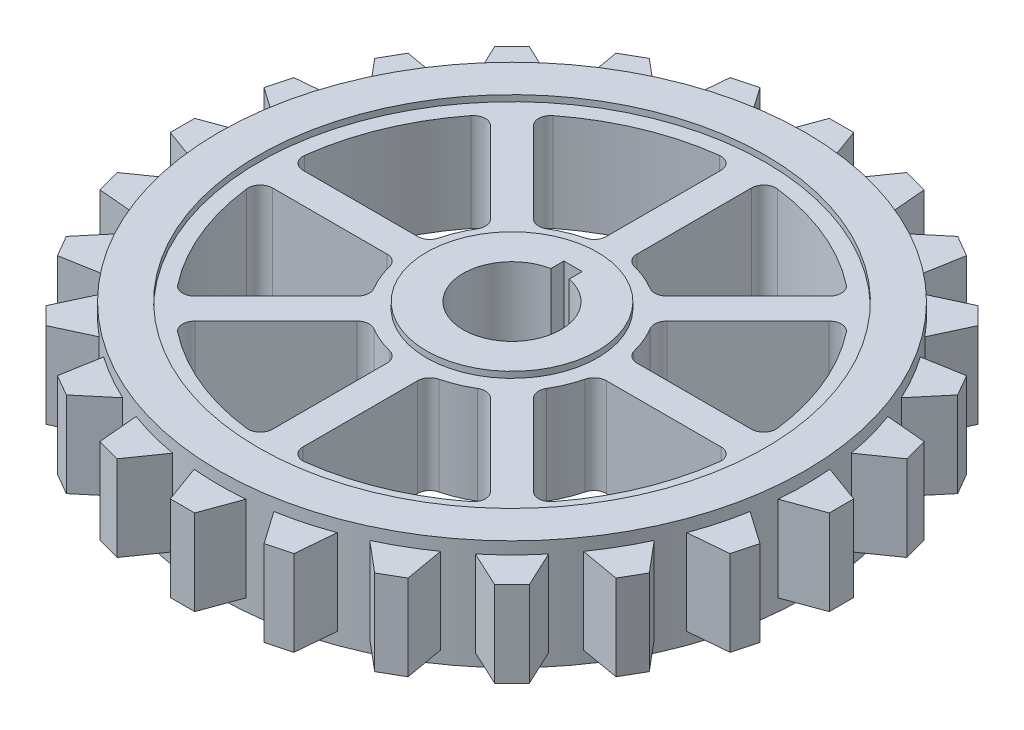
from build123d import *

# Parameters (mm, degrees)
BOSS_EXTRUDE1_DEPTH = 7
SKETCH1_4_R         = 48
SKETCH1_4_R_2       = 41.5
SKETCH1_4_R_3       = 14
BOSS_EXTRUDE2_DEPTH = 9
SKETCH1_5_R         = 41.5
SKETCH1_5_R_2       = 14
BOSS_EXTRUDE3_DEPTH = 8
FILLET2_R           = 2


with BuildPart() as part:
    # Sketch1 → Boss-Extrude1 (new, symmetric)
    with BuildSketch(Plane(origin=(0, 0, 0), x_dir=(1, 0, 0), z_dir=(0, 1, 0))):
        with BuildLine():
            ThreePointArc((8.280626141, 47.280347193), (6.265257227, 47.589353346), (4.238583665, 47.812492181))
            Line((4.238583665, 47.812492181), (2, 53.962950253))
            Line((2, 53.962950253), (-2, 53.962950253))
            Line((-2, 53.962950253), (-4.238583665, 47.812492181))
            ThreePointArc((-4.238583665, 47.812492181), (-6.265257227, 47.589353346), (-8.280626141, 47.280347193))
            Line((-8.280626141, 47.280347193), (-12.034787603, 52.641845402))
            Line((-12.034787603, 52.641845402), (-15.898490908, 51.606569222))
            Line((-15.898490908, 51.606569222), (-16.468940999, 45.08629484))
            ThreePointArc((-16.468940999, 45.08629484), (-18.368804754, 44.346217561), (-20.23552496, 43.526124679))
            Line((-20.23552496, 43.526124679), (-25.249424319, 47.733285782))
            Line((-25.249424319, 47.733285782), (-28.713525934, 45.733285782))
            Line((-28.713525934, 45.733285782), (-27.576967221, 39.287541014))
            ThreePointArc((-27.576967221, 39.287541014), (-29.220548592, 38.080960334), (-30.811406194, 36.805668699))
            Line((-30.811406194, 36.805668699), (-36.743354494, 39.571781619))
            Line((-36.743354494, 39.571781619), (-39.571781619, 36.743354494))
            Line((-39.571781619, 36.743354494), (-36.805668699, 30.811406194))
            ThreePointArc((-36.805668699, 30.811406194), (-38.080960334, 29.220548592), (-39.287541014, 27.576967221))
            Line((-39.287541014, 27.576967221), (-45.733285782, 28.713525934))
            Line((-45.733285782, 28.713525934), (-47.733285782, 25.249424319))
            Line((-47.733285782, 25.249424319), (-43.526124679, 20.23552496))
            ThreePointArc((-43.526124679, 20.23552496), (-44.346217561, 18.368804754), (-45.08629484, 16.468940999))
            Line((-45.08629484, 16.468940999), (-51.606569222, 15.898490908))
            Line((-51.606569222, 15.898490908), (-52.641845402, 12.034787603))
            Line((-52.641845402, 12.034787603), (-47.280347193, 8.280626141))
            ThreePointArc((-47.280347193, 8.280626141), (-47.589353346, 6.265257227), (-47.812492181, 4.238583665))
            Line((-47.812492181, 4.238583665), (-53.962950253, 2))
            Line((-53.962950253, 2), (-53.962950253, -2))
            Line((-53.962950253, -2), (-47.812492181, -4.238583665))
            ThreePointArc((-47.812492181, -4.238583665), (-47.589353346, -6.265257227), (-47.280347193, -8.280626141))
            Line((-47.280347193, -8.280626141), (-52.641845402, -12.034787603))
            Line((-52.641845402, -12.034787603), (-51.606569222, -15.898490908))
            Line((-51.606569222, -15.898490908), (-45.08629484, -16.468940999))
            ThreePointArc((-45.08629484, -16.468940999), (-44.346217561, -18.368804754), (-43.526124679, -20.23552496))
            Line((-43.526124679, -20.23552496), (-47.733285782, -25.249424319))
            Line((-47.733285782, -25.249424319), (-45.733285782, -28.713525934))
            Line((-45.733285782, -28.713525934), (-39.287541014, -27.576967221))
            ThreePointArc((-39.287541014, -27.576967221), (-38.080960334, -29.220548592), (-36.805668699, -30.811406194))
            Line((-36.805668699, -30.811406194), (-39.571781619, -36.743354494))
            Line((-39.571781619, -36.743354494), (-36.743354494, -39.571781619))
            Line((-36.743354494, -39.571781619), (-30.811406194, -36.805668699))
            ThreePointArc((-30.811406194, -36.805668699), (-29.220548592, -38.080960334), (-27.576967221, -39.287541014))
            Line((-27.576967221, -39.287541014), (-28.713525934, -45.733285782))
            Line((-28.713525934, -45.733285782), (-25.249424319, -47.733285782))
            Line((-25.249424319, -47.733285782), (-20.23552496, -43.526124679))
            ThreePointArc((-20.23552496, -43.526124679), (-18.368804754, -44.346217561), (-16.468940999, -45.08629484))
            Line((-16.468940999, -45.08629484), (-15.898490908, -51.606569222))
            Line((-15.898490908, -51.606569222), (-12.034787603, -52.641845402))
            Line((-12.034787603, -52.641845402), (-8.280626141, -47.280347193))
            ThreePointArc((-8.280626141, -47.280347193), (-6.265257227, -47.589353346), (-4.238583665, -47.812492181))
            Line((-4.238583665, -47.812492181), (-2, -53.962950253))
            Line((-2, -53.962950253), (2, -53.962950253))
            Line((2, -53.962950253), (4.238583665, -47.812492181))
            ThreePointArc((4.238583665, -47.812492181), (6.265257227, -47.589353346), (8.280626141, -47.280347193))
            Line((8.280626141, -47.280347193), (12.034787603, -52.641845402))
            Line((12.034787603, -52.641845402), (15.898490908, -51.606569222))
            Line((15.898490908, -51.606569222), (16.468940999, -45.08629484))
            ThreePointArc((16.468940999, -45.08629484), (18.368804754, -44.346217561), (20.23552496, -43.526124679))
            Line((20.23552496, -43.526124679), (25.249424319, -47.733285782))
            Line((25.249424319, -47.733285782), (28.713525934, -45.733285782))
            Line((28.713525934, -45.733285782), (27.576967221, -39.287541014))
            ThreePointArc((27.576967221, -39.287541014), (29.220548592, -38.080960334), (30.811406194, -36.805668699))
            Line((30.811406194, -36.805668699), (36.743354494, -39.571781619))
            Line((36.743354494, -39.571781619), (39.571781619, -36.743354494))
            Line((39.571781619, -36.743354494), (36.805668699, -30.811406194))
            ThreePointArc((36.805668699, -30.811406194), (38.080960334, -29.220548592), (39.287541014, -27.576967221))
            Line((39.287541014, -27.576967221), (45.733285782, -28.713525934))
            Line((45.733285782, -28.713525934), (47.733285782, -25.249424319))
            Line((47.733285782, -25.249424319), (43.526124679, -20.23552496))
            ThreePointArc((43.526124679, -20.23552496), (44.346217561, -18.368804754), (45.08629484, -16.468940999))
            Line((45.08629484, -16.468940999), (51.606569222, -15.898490908))
            Line((51.606569222, -15.898490908), (52.641845402, -12.034787603))
            Line((52.641845402, -12.034787603), (47.280347193, -8.280626141))
            ThreePointArc((47.280347193, -8.280626141), (47.589353346, -6.265257227), (47.812492181, -4.238583665))
            Line((47.812492181, -4.238583665), (53.962950253, -2))
            Line((53.962950253, -2), (53.962950253, 2))
            Line((53.962950253, 2), (47.812492181, 4.238583665))
            ThreePointArc((47.812492181, 4.238583665), (47.589353346, 6.265257227), (47.280347193, 8.280626141))
            Line((47.280347193, 8.280626141), (52.641845402, 12.034787603))
            Line((52.641845402, 12.034787603), (51.606569222, 15.898490908))
            Line((51.606569222, 15.898490908), (45.08629484, 16.468940999))
            ThreePointArc((45.08629484, 16.468940999), (44.346217561, 18.368804754), (43.526124679, 20.23552496))
            Line((43.526124679, 20.23552496), (47.733285782, 25.249424319))
            Line((47.733285782, 25.249424319), (45.733285782, 28.713525934))
            Line((45.733285782, 28.713525934), (39.287541014, 27.576967221))
            ThreePointArc((39.287541014, 27.576967221), (38.080960334, 29.220548592), (36.805668699, 30.811406194))
            Line((36.805668699, 30.811406194), (39.571781619, 36.743354494))
            Line((39.571781619, 36.743354494), (36.743354494, 39.571781619))
            Line((36.743354494, 39.571781619), (30.811406194, 36.805668699))
            ThreePointArc((30.811406194, 36.805668699), (29.220548592, 38.080960334), (27.576967221, 39.287541014))
            Line((27.576967221, 39.287541014), (28.713525934, 45.733285782))
            Line((28.713525934, 45.733285782), (25.249424319, 47.733285782))
            Line((25.249424319, 47.733285782), (20.23552496, 43.526124679))
            ThreePointArc((20.23552496, 43.526124679), (18.368804754, 44.346217561), (16.468940999, 45.08629484))
            Line((16.468940999, 45.08629484), (15.898490908, 51.606569222))
            Line((15.898490908, 51.606569222), (12.034787603, 52.641845402))
            Line((12.034787603, 52.641845402), (8.280626141, 47.280347193))
        make_face()
        with BuildLine():
            Line((2.5, 16.30950643), (2.5, 38.919789311))
            ThreePointArc((2.5, 38.919789311), (14.924653862, 36.031301768), (25.752679991, 29.288213897))
            Line((25.752679991, 29.288213897), (9.764795642, 13.300329548))
            ThreePointArc((9.764795642, 13.300329548), (6.314276634, 15.244012286), (2.5, 16.30950643))
        make_face(mode=Mode.SUBTRACT)
        with BuildLine():
            ThreePointArc((-9.764795642, -13.300329548), (-6.314276634, -15.244012286), (-2.5, -16.30950643))
            Line((-2.5, -16.30950643), (-2.5, -38.919789311))
            ThreePointArc((-2.5, -38.919789311), (-14.924653862, -36.031301768), (-25.752679991, -29.288213897))
            Line((-25.752679991, -29.288213897), (-9.764795642, -13.300329548))
        make_face(mode=Mode.SUBTRACT)
        with BuildLine():
            ThreePointArc((-16.30950643, -2.5), (-15.244012286, -6.314276634), (-13.300329548, -9.764795642))
            Line((-13.300329548, -9.764795642), (-29.288213897, -25.752679991))
            ThreePointArc((-29.288213897, -25.752679991), (-36.031301768, -14.924653862), (-38.919789311, -2.5))
            Line((-38.919789311, -2.5), (-16.30950643, -2.5))
        make_face(mode=Mode.SUBTRACT)
        with BuildLine():
            ThreePointArc((2.5, -16.30950643), (6.314276634, -15.244012286), (9.764795642, -13.300329548))
            Line((9.764795642, -13.300329548), (25.752679991, -29.288213897))
            ThreePointArc((25.752679991, -29.288213897), (14.924653862, -36.031301768), (2.5, -38.919789311))
            Line((2.5, -38.919789311), (2.5, -16.30950643))
        make_face(mode=Mode.SUBTRACT)
        with BuildLine():
            ThreePointArc((13.300329548, -9.764795642), (15.244012286, -6.314276634), (16.30950643, -2.5))
            Line((16.30950643, -2.5), (38.919789311, -2.5))
            ThreePointArc((38.919789311, -2.5), (36.031301768, -14.924653862), (29.288213897, -25.752679991))
            Line((29.288213897, -25.752679991), (13.300329548, -9.764795642))
        make_face(mode=Mode.SUBTRACT)
        with BuildLine():
            ThreePointArc((-13.300329548, 9.764795642), (-15.244012286, 6.314276634), (-16.30950643, 2.5))
            Line((-16.30950643, 2.5), (-38.919789311, 2.5))
            ThreePointArc((-38.919789311, 2.5), (-36.031301768, 14.924653862), (-29.288213897, 25.752679991))
            Line((-29.288213897, 25.752679991), (-13.300329548, 9.764795642))
        make_face(mode=Mode.SUBTRACT)
        with BuildLine():
            Line((-2.5, 38.919789311), (-2.5, 16.30950643))
            ThreePointArc((-2.5, 16.30950643), (-6.314276634, 15.244012286), (-9.764795642, 13.300329548))
            Line((-9.764795642, 13.300329548), (-25.752679991, 29.288213897))
            ThreePointArc((-25.752679991, 29.288213897), (-14.924653862, 36.031301768), (-2.5, 38.919789311))
        make_face(mode=Mode.SUBTRACT)
        with BuildLine():
            ThreePointArc((16.30950643, 2.5), (15.244012286, 6.314276634), (13.300329548, 9.764795642))
            Line((13.300329548, 9.764795642), (29.288213897, 25.752679991))
            ThreePointArc((29.288213897, 25.752679991), (36.031301768, 14.924653862), (38.919789311, 2.5))
            Line((38.919789311, 2.5), (16.30950643, 2.5))
        make_face(mode=Mode.SUBTRACT)
        with BuildLine():
            Line((-1.5, 7.858116823), (-1.5, 10))
            Line((-1.5, 10), (1.5, 10))
            Line((1.5, 10), (1.5, 7.858116823))
            ThreePointArc((1.5, 7.858116823), (0, -8), (-1.5, 7.858116823))
        make_face(mode=Mode.SUBTRACT)
    extrude(amount=BOSS_EXTRUDE1_DEPTH, both=True)

    # Sketch1_4 → Boss-Extrude2 (add, symmetric)
    # profile 1 of 2: a face of its own
    with BuildSketch(Plane(origin=(0, 0, 0), x_dir=(1, 0, 0), z_dir=(0, 1, 0))):
        Circle(SKETCH1_4_R)
        Circle(SKETCH1_4_R_2, mode=Mode.SUBTRACT)
    # profile 2 of 2: a face of its own
    with BuildSketch(Plane(origin=(0, 0, 0), x_dir=(1, 0, 0), z_dir=(0, 1, 0))):
        Circle(SKETCH1_4_R_3)
        with BuildLine():
            ThreePointArc((1.5, 7.858116823), (0, -8), (-1.5, 7.858116823))
            Line((-1.5, 7.858116823), (-1.5, 10))
            Line((-1.5, 10), (1.5, 10))
            Line((1.5, 10), (1.5, 7.858116823))
        make_face(mode=Mode.SUBTRACT)
    extrude(amount=BOSS_EXTRUDE2_DEPTH, both=True)

    # Sketch1_5 → Boss-Extrude3 (add, symmetric)
    with BuildSketch(Plane(origin=(0, 0, 0), x_dir=(1, 0, 0), z_dir=(0, 1, 0))):
        Circle(SKETCH1_5_R)
        with BuildLine():
            ThreePointArc((-9.764795642, -13.300329548), (-6.314276634, -15.244012286), (-2.5, -16.30950643))
            Line((-2.5, -16.30950643), (-2.5, -38.919789311))
            ThreePointArc((-2.5, -38.919789311), (-14.924653862, -36.031301768), (-25.752679991, -29.288213897))
            Line((-25.752679991, -29.288213897), (-9.764795642, -13.300329548))
        make_face(mode=Mode.SUBTRACT)
        with BuildLine():
            ThreePointArc((-16.30950643, -2.5), (-15.244012286, -6.314276634), (-13.300329548, -9.764795642))
            Line((-13.300329548, -9.764795642), (-29.288213897, -25.752679991))
            ThreePointArc((-29.288213897, -25.752679991), (-36.031301768, -14.924653862), (-38.919789311, -2.5))
            Line((-38.919789311, -2.5), (-16.30950643, -2.5))
        make_face(mode=Mode.SUBTRACT)
        with BuildLine():
            ThreePointArc((2.5, -16.30950643), (6.314276634, -15.244012286), (9.764795642, -13.300329548))
            Line((9.764795642, -13.300329548), (25.752679991, -29.288213897))
            ThreePointArc((25.752679991, -29.288213897), (14.924653862, -36.031301768), (2.5, -38.919789311))
            Line((2.5, -38.919789311), (2.5, -16.30950643))
        make_face(mode=Mode.SUBTRACT)
        with BuildLine():
            ThreePointArc((13.300329548, -9.764795642), (15.244012286, -6.314276634), (16.30950643, -2.5))
            Line((16.30950643, -2.5), (38.919789311, -2.5))
            ThreePointArc((38.919789311, -2.5), (36.031301768, -14.924653862), (29.288213897, -25.752679991))
            Line((29.288213897, -25.752679991), (13.300329548, -9.764795642))
        make_face(mode=Mode.SUBTRACT)
        with BuildLine():
            ThreePointArc((-13.300329548, 9.764795642), (-15.244012286, 6.314276634), (-16.30950643, 2.5))
            Line((-16.30950643, 2.5), (-38.919789311, 2.5))
            ThreePointArc((-38.919789311, 2.5), (-36.031301768, 14.924653862), (-29.288213897, 25.752679991))
            Line((-29.288213897, 25.752679991), (-13.300329548, 9.764795642))
        make_face(mode=Mode.SUBTRACT)
        with BuildLine():
            Line((-2.5, 38.919789311), (-2.5, 16.30950643))
            ThreePointArc((-2.5, 16.30950643), (-6.314276634, 15.244012286), (-9.764795642, 13.300329548))
            Line((-9.764795642, 13.300329548), (-25.752679991, 29.288213897))
            ThreePointArc((-25.752679991, 29.288213897), (-14.924653862, 36.031301768), (-2.5, 38.919789311))
        make_face(mode=Mode.SUBTRACT)
        Circle(SKETCH1_5_R_2, mode=Mode.SUBTRACT)
        with BuildLine():
            ThreePointArc((16.30950643, 2.5), (15.244012286, 6.314276634), (13.300329548, 9.764795642))
            Line((13.300329548, 9.764795642), (29.288213897, 25.752679991))
            ThreePointArc((29.288213897, 25.752679991), (36.031301768, 14.924653862), (38.919789311, 2.5))
            Line((38.919789311, 2.5), (16.30950643, 2.5))
        make_face(mode=Mode.SUBTRACT)
        with BuildLine():
            ThreePointArc((9.764795642, 13.300329548), (6.314276634, 15.244012286), (2.5, 16.30950643))
            Line((2.5, 16.30950643), (2.5, 38.919789311))
            ThreePointArc((2.5, 38.919789311), (14.924653862, 36.031301768), (25.752679991, 29.288213897))
            Line((25.752679991, 29.288213897), (9.764795642, 13.300329548))
        make_face(mode=Mode.SUBTRACT)
    extrude(amount=BOSS_EXTRUDE3_DEPTH, both=True)

    # Fillet2
    fillet2_edges = [part.edges().sort_by_distance(p)[0] for p in [
        (-38.919789311, 0, 2.5),
        (-29.288213897, 0, 25.752679991),
        (-13.300329548, 0, 9.764795642),
        (-16.30950643, 0, 2.5),
        (-25.752679991, 0, 29.288213897),
        (-2.5, 0, 38.919789311),
        (-2.5, 0, 16.30950643),
        (-9.764795642, 0, 13.300329548),
        (2.5, 0, 38.919789311),
        (25.752679991, 0, 29.288213897),
        (9.764795642, 0, 13.300329548),
        (2.5, 0, 16.30950643),
        (29.288213897, 0, 25.752679991),
        (38.919789311, 0, 2.5),
        (16.30950643, 0, 2.5),
        (13.300329548, 0, 9.764795642),
        (38.919789311, 0, -2.5),
        (29.288213897, 0, -25.752679991),
        (13.300329548, 0, -9.764795642),
        (16.30950643, 0, -2.5),
        (25.752679991, 0, -29.288213897),
        (2.5, 0, -38.919789311),
        (2.5, 0, -16.30950643),
        (9.764795642, 0, -13.300329548),
        (-9.764795642, 0, -13.300329548),
        (-2.5, 0, -16.30950643),
        (-29.288213897, 0, -25.752679991),
        (-38.919789311, 0, -2.5),
        (-16.30950643, 0, -2.5),
        (-13.300329548, 0, -9.764795642),
        (-25.752679991, 0, -29.288213897),
        (-2.5, 0, -38.919789311),
    ]]
    fillet(fillet2_edges, radius=FILLET2_R)


solid = part.part
